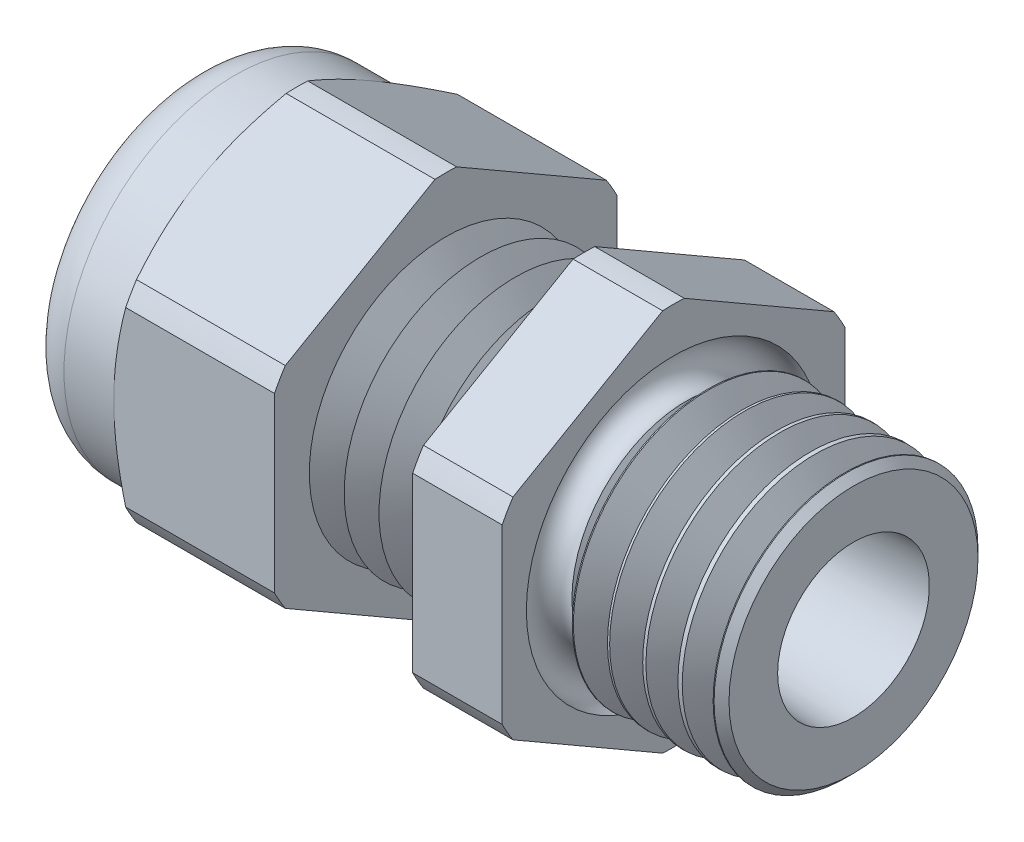
from build123d import *

# Parameters (mm, degrees)
SKETCH2_OUTSIDE_W  = 26.272
SKETCH2_OUTSIDE_H  = 26.272
CUT_EXTRUDE1_DEPTH = 16.98625
CHAMFER1_SIZE      = 0.326149358
CHAMFER1_SIZE2     = 0.3175
SKETCH3_OUTSIDE_W  = 113.902
SKETCH3_OUTSIDE_H  = 115.7
SKETCH3_OUTSIDE_R  = 7.493
CUT_EXTRUDE2_DEPTH = 25.86025
CUT_EXTRUDE2_DRAFT = -60
SKETCH14_W         = 4.09575
SKETCH14_H         = 1.524
FILLET1_R          = 1.91516
LPATTERN1_COUNT    = 4
LPATTERN1_PITCH    = 1.524
LPATTERN2_COUNT    = 6
LPATTERN2_PITCH    = 1.524
SKETCH15_R         = 0.8255


with BuildPart() as part:
    # Sketch1 → Revolve1 (revolve)
    with BuildSketch(Plane.XY, mode=Mode.PRIVATE) as revolve1_sk:
        Polygon((-9.958916667, 5.969), (-9.958916667, 8.39216), (-16.98625, 8.39216), (-16.98625, 5.969), (-21.082, 5.969), (-21.082, 5.07365), (-16.98625, 5.07365), (-16.98625, 2.54), (-9.958916667, 2.54), (7.874, 3.318601956), (7.874, 5.762812054), (0, 5.969), (0, 8.39216), (-3.917412935, 8.39216), (-3.917412935, 5.969), align=None)
    revolve(revolve1_sk.sketch.rotate(Axis((-18.386021217, 0, 0), (1, 0, 0)), 90), axis=Axis((-18.386021217, 0, 0), (1, 0, 0)))  # turned: the seam where the file's is

    # Sketch2 outside → Cut-Extrude1 (cut)
    with BuildSketch(Plane(origin=(0, 0, 0), x_dir=(0, 0, -1), z_dir=(1, 0, 0))):
        Rectangle(SKETCH2_OUTSIDE_W, SKETCH2_OUTSIDE_H)
        with BuildLine():
            Line((7.493, -3.779325398), (7.493, 3.779325398))
            ThreePointArc((7.493, 3.779325398), (7.267823753, 4.19608), (7.019491804, 4.599465651))
            Line((7.019491804, 4.599465651), (0.473508196, 8.37879105))
            ThreePointArc((0.473508196, 8.37879105), (0, 8.39216), (-0.473508196, 8.37879105))
            Line((-0.473508196, 8.37879105), (-7.019491804, 4.599465651))
            ThreePointArc((-7.019491804, 4.599465651), (-7.267823753, 4.19608), (-7.493, 3.779325398))
            Line((-7.493, 3.779325398), (-7.493, -3.779325398))
            ThreePointArc((-7.493, -3.779325398), (-7.267823753, -4.19608), (-7.019491804, -4.599465651))
            Line((-7.019491804, -4.599465651), (-0.473508196, -8.37879105))
            ThreePointArc((-0.473508196, -8.37879105), (0, -8.39216), (0.473508196, -8.37879105))
            Line((0.473508196, -8.37879105), (7.019491804, -4.599465651))
            ThreePointArc((7.019491804, -4.599465651), (7.267823753, -4.19608), (7.493, -3.779325398))
        make_face(mode=Mode.SUBTRACT)
    extrude(amount=-CUT_EXTRUDE1_DEPTH, mode=Mode.SUBTRACT)

    # Chamfer1
    chamfer1_edges = [part.edges().sort_by_distance(p)[0] for p in [
        (7.874, 0, -5.762812054),
    ]]
    chamfer1_side = [part.faces().sort_by_distance(p)[0] for p in [
        (3.937, 0, -5.865906027),
    ]]
    chamfer(chamfer1_edges, length=CHAMFER1_SIZE, length2=CHAMFER1_SIZE2, reference=chamfer1_side[0])


with BuildPart() as cut_extrude2_tool:
    # Sketch3 outside → Cut-Extrude2 (with draft: the straight prism first)
    with BuildSketch(Plane.ZY.offset(16.98625)):
        Rectangle(SKETCH3_OUTSIDE_W, SKETCH3_OUTSIDE_H)
        Circle(SKETCH3_OUTSIDE_R, mode=Mode.SUBTRACT)
    extrude(amount=-CUT_EXTRUDE2_DEPTH)
    # Cut-Extrude2: the draft: its side faces are tilted about the plane it starts from
    cut_extrude2_sides = [cut_extrude2_tool.faces().sort_by_distance(p)[0] for p in [
        (-4.056125, -57.85, 0),
        (-4.056125, 0, 56.951),
        (-4.056125, 57.85, 0),
        (-4.056125, 0, -56.951),
        (-4.056125, 0, -7.493),
    ]]
    draft(cut_extrude2_sides, Plane.ZY.offset(16.98625), CUT_EXTRUDE2_DRAFT)


with BuildPart() as part_1:
    add(part.part)

    # Cut-Extrude2: cut by cut_extrude2_tool
    add(cut_extrude2_tool.part, mode=Mode.SUBTRACT)

    # Sketch14 → Revolve4 (revolve)
    with BuildSketch(Plane.XY, mode=Mode.PRIVATE) as revolve4_sk:
        with Locations((-19.034125, 6.731)):
            Rectangle(SKETCH14_W, SKETCH14_H)
    revolve(revolve4_sk.sketch.rotate(Axis((-18.386021217, 0, 0), (1, 0, 0)), 90), axis=Axis((-18.386021217, 0, 0), (1, 0, 0)))  # turned: the seam where the file's is

    # Fillet1
    fillet1_edges = [part_1.edges().sort_by_distance(p)[0] for p in [
        (-21.082, 0, -7.493),
    ]]
    fillet(fillet1_edges, radius=FILLET1_R)

    # Sketch10 → Cut-Revolve1 (revolve, cut)
    with BuildSketch(Plane.XY, mode=Mode.PRIVATE) as cut_revolve1_sk:
        Polygon((-9.958916667, 5.969), (-9.196917022, 4.6491779), (-8.434917377, 5.969), align=None)
    cut_revolve1 = revolve(cut_revolve1_sk.sketch.rotate(Axis((15.58962545, 0, 0), (-1, 0, 0)), 270), axis=Axis((15.58962545, 0, 0), (-1, 0, 0)), mode=Mode.SUBTRACT)  # turned: the seam where the file's is

    # LPattern1: Cut-Revolve1 ×4
    with Locations(*[(i * LPATTERN1_PITCH, 0, 0) for i in range(1, LPATTERN1_COUNT)]):
        add(cut_revolve1, mode=Mode.SUBTRACT)

    # Sketch13 → Cut-Revolve2 (revolve, cut)
    with BuildSketch(Plane.XY, mode=Mode.PRIVATE) as cut_revolve2_sk:
        Polygon((0, 5.969), (1.523999289, 5.969), (0.761999645, 4.6491779), align=None)
    cut_revolve2 = revolve(cut_revolve2_sk.sketch.rotate(Axis((-18.386021217, 0, 0), (1, 0, 0)), 270), axis=Axis((-18.386021217, 0, 0), (1, 0, 0)), mode=Mode.SUBTRACT)  # turned: the seam where the file's is

    # LPattern2: Cut-Revolve2 ×6
    with Locations(*[(i * LPATTERN2_PITCH, 0, 0) for i in range(1, LPATTERN2_COUNT)]):
        add(cut_revolve2, mode=Mode.SUBTRACT)

    # Sketch15 → Cut-Revolve3 (revolve, cut)
    with BuildSketch(Plane.XY, mode=Mode.PRIVATE) as cut_revolve3_sk:
        with Locations((0, -5.609698712)):
            Circle(SKETCH15_R)
    revolve(cut_revolve3_sk.sketch.rotate(Axis((1.524, 0, 0), (-1, 0, 0)), 90), axis=Axis((1.524, 0, 0), (-1, 0, 0)), mode=Mode.SUBTRACT)  # turned: the seam where the file's is


with BuildPart() as body_2:
    # Sketch16 → Revolve5 (revolve)
    with BuildSketch(Plane.XY, mode=Mode.PRIVATE) as revolve5_sk:
        with BuildLine():
            Line((-20.066, 5.07365), (-16.98625, 5.07365))
            Line((-16.98625, 5.07365), (-16.98625, 2.54))
            Line((-16.98625, 2.54), (-20.32, 2.54))
            Line((-20.32, 2.54), (-20.32, 4.81965))
            ThreePointArc((-20.32, 4.81965), (-20.245605122, 4.999255122), (-20.066, 5.07365))
        make_face()
    revolve(revolve5_sk.sketch.rotate(Axis((-18.386021217, 0, 0), (1, 0, 0)), 90), axis=Axis((-18.386021217, 0, 0), (1, 0, 0)))  # turned: the seam where the file's is


solid = Compound([part_1.part, body_2.part])
